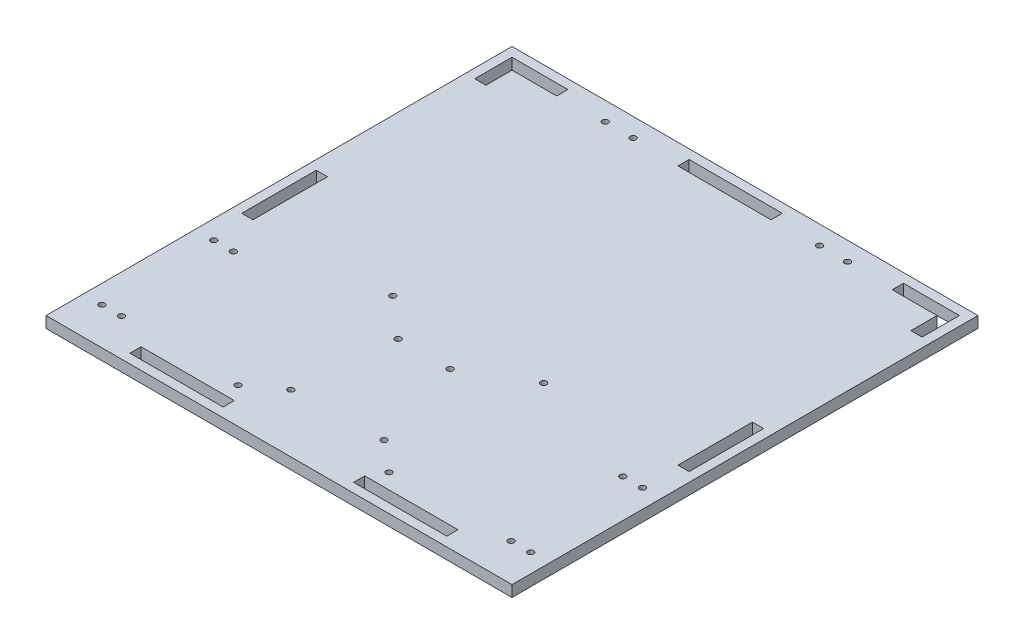
from build123d import *

# Parameters (mm, degrees)
SKETCH1_W           = 250
SKETCH1_H           = 250
BOSS_EXTRUDE1_DEPTH = 6
CUT_EXTRUDE2_REACH  = 8
SKETCH4_R           = 1.6
CUT_EXTRUDE3_REACH  = 8
SKETCH5_R           = 1.6
SKETCH6_W           = 6
SKETCH6_H           = 40
SKETCH6_W_2         = 50
SKETCH6_H_2         = 6
CUT_EXTRUDE6_DEPTH  = 6
CUT_EXTRUDE7_REACH  = 8
SKETCH7_R           = 1.6
CUT_EXTRUDE8_REACH  = 8
SKETCH8_R           = 1.6


with BuildPart() as part:
    # Sketch1 → Boss-Extrude1 (new body)
    with BuildSketch(Plane(origin=(0, 0, 0), x_dir=(1, 0, 0), z_dir=(0, 1, 0))):
        Rectangle(SKETCH1_W, SKETCH1_H)
    extrude(amount=BOSS_EXTRUDE1_DEPTH)

    # Sketch4 → Cut-Extrude2 (cut, up to next)
    with BuildSketch(Plane(origin=(0, 6, 0), x_dir=(1, 0, 0), z_dir=(0, 1, 0)), mode=Mode.PRIVATE) as cut_extrude2_sk1:
        with Locations((-115, -105)):
            Circle(SKETCH4_R)
    cut_extrude2_tool1 = extrude(cut_extrude2_sk1.sketch, amount=-CUT_EXTRUDE2_REACH, mode=Mode.PRIVATE) & part.part
    add(cut_extrude2_tool1.solids().sort_by_distance((-115, 6, 105))[0], mode=Mode.SUBTRACT)
    # Sketch4 → Cut-Extrude2 (cut, up to next)
    with BuildSketch(Plane(origin=(0, 6, 0), x_dir=(1, 0, 0), z_dir=(0, 1, 0)), mode=Mode.PRIVATE) as cut_extrude2_sk2:
        with Locations((-104.5, -105)):
            Circle(SKETCH4_R)
    cut_extrude2_tool2 = extrude(cut_extrude2_sk2.sketch, amount=-CUT_EXTRUDE2_REACH, mode=Mode.PRIVATE) & part.part
    add(cut_extrude2_tool2.solids().sort_by_distance((-104.5, 6, 105))[0], mode=Mode.SUBTRACT)
    # Sketch4 → Cut-Extrude2 (cut, up to next)
    with BuildSketch(Plane(origin=(0, 6, 0), x_dir=(1, 0, 0), z_dir=(0, 1, 0)), mode=Mode.PRIVATE) as cut_extrude2_sk3:
        with Locations((-115, -45)):
            Circle(SKETCH4_R)
    cut_extrude2_tool3 = extrude(cut_extrude2_sk3.sketch, amount=-CUT_EXTRUDE2_REACH, mode=Mode.PRIVATE) & part.part
    add(cut_extrude2_tool3.solids().sort_by_distance((-115, 6, 45))[0], mode=Mode.SUBTRACT)
    # Sketch4 → Cut-Extrude2 (cut, up to next)
    with BuildSketch(Plane(origin=(0, 6, 0), x_dir=(1, 0, 0), z_dir=(0, 1, 0)), mode=Mode.PRIVATE) as cut_extrude2_sk4:
        with Locations((-104.5, -45)):
            Circle(SKETCH4_R)
    cut_extrude2_tool4 = extrude(cut_extrude2_sk4.sketch, amount=-CUT_EXTRUDE2_REACH, mode=Mode.PRIVATE) & part.part
    add(cut_extrude2_tool4.solids().sort_by_distance((-104.5, 6, 45))[0], mode=Mode.SUBTRACT)
    # Sketch4 → Cut-Extrude2 (cut, up to next)
    with BuildSketch(Plane(origin=(0, 6, 0), x_dir=(1, 0, 0), z_dir=(0, 1, 0)), mode=Mode.PRIVATE) as cut_extrude2_sk5:
        with Locations((115, -45)):
            Circle(SKETCH4_R)
    cut_extrude2_tool5 = extrude(cut_extrude2_sk5.sketch, amount=-CUT_EXTRUDE2_REACH, mode=Mode.PRIVATE) & part.part
    add(cut_extrude2_tool5.solids().sort_by_distance((115, 6, 45))[0], mode=Mode.SUBTRACT)
    # Sketch4 → Cut-Extrude2 (cut, up to next)
    with BuildSketch(Plane(origin=(0, 6, 0), x_dir=(1, 0, 0), z_dir=(0, 1, 0)), mode=Mode.PRIVATE) as cut_extrude2_sk6:
        with Locations((104.5, -45)):
            Circle(SKETCH4_R)
    cut_extrude2_tool6 = extrude(cut_extrude2_sk6.sketch, amount=-CUT_EXTRUDE2_REACH, mode=Mode.PRIVATE) & part.part
    add(cut_extrude2_tool6.solids().sort_by_distance((104.5, 6, 45))[0], mode=Mode.SUBTRACT)
    # Sketch4 → Cut-Extrude2 (cut, up to next)
    with BuildSketch(Plane(origin=(0, 6, 0), x_dir=(1, 0, 0), z_dir=(0, 1, 0)), mode=Mode.PRIVATE) as cut_extrude2_sk7:
        with Locations((115, -105)):
            Circle(SKETCH4_R)
    cut_extrude2_tool7 = extrude(cut_extrude2_sk7.sketch, amount=-CUT_EXTRUDE2_REACH, mode=Mode.PRIVATE) & part.part
    add(cut_extrude2_tool7.solids().sort_by_distance((115, 6, 105))[0], mode=Mode.SUBTRACT)
    # Sketch4 → Cut-Extrude2 (cut, up to next)
    with BuildSketch(Plane(origin=(0, 6, 0), x_dir=(1, 0, 0), z_dir=(0, 1, 0)), mode=Mode.PRIVATE) as cut_extrude2_sk8:
        with Locations((104.5, -105)):
            Circle(SKETCH4_R)
    cut_extrude2_tool8 = extrude(cut_extrude2_sk8.sketch, amount=-CUT_EXTRUDE2_REACH, mode=Mode.PRIVATE) & part.part
    add(cut_extrude2_tool8.solids().sort_by_distance((104.5, 6, 105))[0], mode=Mode.SUBTRACT)

    # Sketch5 → Cut-Extrude3 (cut, up to next)
    with BuildSketch(Plane(origin=(0, 6, 0), x_dir=(1, 0, 0), z_dir=(0, 1, 0)), mode=Mode.PRIVATE) as cut_extrude3_sk1:
        with Locations((-65, 115)):
            Circle(SKETCH5_R)
    cut_extrude3_tool1 = extrude(cut_extrude3_sk1.sketch, amount=-CUT_EXTRUDE3_REACH, mode=Mode.PRIVATE) & part.part
    add(cut_extrude3_tool1.solids().sort_by_distance((-65, 6, -115))[0], mode=Mode.SUBTRACT)
    # Sketch5 → Cut-Extrude3 (cut, up to next)
    with BuildSketch(Plane(origin=(0, 6, 0), x_dir=(1, 0, 0), z_dir=(0, 1, 0)), mode=Mode.PRIVATE) as cut_extrude3_sk2:
        with Locations((-50, 115)):
            Circle(SKETCH5_R)
    cut_extrude3_tool2 = extrude(cut_extrude3_sk2.sketch, amount=-CUT_EXTRUDE3_REACH, mode=Mode.PRIVATE) & part.part
    add(cut_extrude3_tool2.solids().sort_by_distance((-50, 6, -115))[0], mode=Mode.SUBTRACT)
    # Sketch5 → Cut-Extrude3 (cut, up to next)
    with BuildSketch(Plane(origin=(0, 6, 0), x_dir=(1, 0, 0), z_dir=(0, 1, 0)), mode=Mode.PRIVATE) as cut_extrude3_sk3:
        with Locations((50, 115)):
            Circle(SKETCH5_R)
    cut_extrude3_tool3 = extrude(cut_extrude3_sk3.sketch, amount=-CUT_EXTRUDE3_REACH, mode=Mode.PRIVATE) & part.part
    add(cut_extrude3_tool3.solids().sort_by_distance((50, 6, -115))[0], mode=Mode.SUBTRACT)
    # Sketch5 → Cut-Extrude3 (cut, up to next)
    with BuildSketch(Plane(origin=(0, 6, 0), x_dir=(1, 0, 0), z_dir=(0, 1, 0)), mode=Mode.PRIVATE) as cut_extrude3_sk4:
        with Locations((65, 115)):
            Circle(SKETCH5_R)
    cut_extrude3_tool4 = extrude(cut_extrude3_sk4.sketch, amount=-CUT_EXTRUDE3_REACH, mode=Mode.PRIVATE) & part.part
    add(cut_extrude3_tool4.solids().sort_by_distance((65, 6, -115))[0], mode=Mode.SUBTRACT)

    # Sketch6 → Cut-Extrude6 (cut)
    with BuildSketch(Plane(origin=(0, 6, 0), x_dir=(1, 0, 0), z_dir=(0, 1, 0))):
        Polygon((-90, 120), (-120, 120), (-120, 100), (-114, 100), (-114, 114), (-90, 114), align=None)
        with Locations((-117, -5)):
            Rectangle(SKETCH6_W, SKETCH6_H)
        with Locations((-60, -117)):
            Rectangle(SKETCH6_W_2, SKETCH6_H_2)
        with Locations((60, -117)):
            Rectangle(SKETCH6_W_2, SKETCH6_H_2)
        Polygon((120, 100), (120, 120), (90, 120), (90, 114), (114, 114), (114, 100), align=None)
        with Locations((117, -5)):
            Rectangle(SKETCH6_W, SKETCH6_H)
        with Locations((0, 117)):
            Rectangle(SKETCH6_W_2, SKETCH6_H_2)
    extrude(amount=-CUT_EXTRUDE6_DEPTH, mode=Mode.SUBTRACT)

    # Sketch7 → Cut-Extrude7 (cut, up to next)
    with BuildSketch(Plane(origin=(0, 0, 0), x_dir=(-1, 0, 0), z_dir=(0, -1, 0)), mode=Mode.PRIVATE) as cut_extrude7_sk1:
        with Locations((19.693028717, -41.4)):
            Circle(SKETCH7_R)
    cut_extrude7_tool1 = extrude(cut_extrude7_sk1.sketch, amount=-CUT_EXTRUDE7_REACH, mode=Mode.PRIVATE) & part.part
    add(cut_extrude7_tool1.solids().sort_by_distance((-19.693029, 0, 41.4))[0], mode=Mode.SUBTRACT)
    # Sketch7 → Cut-Extrude7 (cut, up to next)
    with BuildSketch(Plane(origin=(0, 0, 0), x_dir=(-1, 0, 0), z_dir=(0, -1, 0)), mode=Mode.PRIVATE) as cut_extrude7_sk2:
        with Locations((-8.206971283, -41.4)):
            Circle(SKETCH7_R)
    cut_extrude7_tool2 = extrude(cut_extrude7_sk2.sketch, amount=-CUT_EXTRUDE7_REACH, mode=Mode.PRIVATE) & part.part
    add(cut_extrude7_tool2.solids().sort_by_distance((8.206971, 0, 41.4))[0], mode=Mode.SUBTRACT)
    # Sketch7 → Cut-Extrude7 (cut, up to next)
    with BuildSketch(Plane(origin=(0, 0, 0), x_dir=(-1, 0, 0), z_dir=(0, -1, 0)), mode=Mode.PRIVATE) as cut_extrude7_sk3:
        with Locations((-23.506971283, -92.2)):
            Circle(SKETCH7_R)
    cut_extrude7_tool3 = extrude(cut_extrude7_sk3.sketch, amount=-CUT_EXTRUDE7_REACH, mode=Mode.PRIVATE) & part.part
    add(cut_extrude7_tool3.solids().sort_by_distance((23.506971, 0, 92.2))[0], mode=Mode.SUBTRACT)
    # Sketch7 → Cut-Extrude7 (cut, up to next)
    with BuildSketch(Plane(origin=(0, 0, 0), x_dir=(-1, 0, 0), z_dir=(0, -1, 0)), mode=Mode.PRIVATE) as cut_extrude7_sk4:
        with Locations((24.793028717, -93.8)):
            Circle(SKETCH7_R)
    cut_extrude7_tool4 = extrude(cut_extrude7_sk4.sketch, amount=-CUT_EXTRUDE7_REACH, mode=Mode.PRIVATE) & part.part
    add(cut_extrude7_tool4.solids().sort_by_distance((-24.793029, 0, 93.8))[0], mode=Mode.SUBTRACT)

    # Sketch8 → Cut-Extrude8 (cut, up to next)
    with BuildSketch(Plane(origin=(0, 0, 0), x_dir=(-1, 0, 0), z_dir=(0, -1, 0)), mode=Mode.PRIVATE) as cut_extrude8_sk1:
        with Locations((41.143028717, -105.838250208)):
            Circle(SKETCH8_R)
    cut_extrude8_tool1 = extrude(cut_extrude8_sk1.sketch, amount=-CUT_EXTRUDE8_REACH, mode=Mode.PRIVATE) & part.part
    add(cut_extrude8_tool1.solids().sort_by_distance((-41.143029, 0, 105.83825))[0], mode=Mode.SUBTRACT)
    # Sketch8 → Cut-Extrude8 (cut, up to next)
    with BuildSketch(Plane(origin=(0, 0, 0), x_dir=(-1, 0, 0), z_dir=(0, -1, 0)), mode=Mode.PRIVATE) as cut_extrude8_sk2:
        with Locations((41.143028717, -22.838250208)):
            Circle(SKETCH8_R)
    cut_extrude8_tool2 = extrude(cut_extrude8_sk2.sketch, amount=-CUT_EXTRUDE8_REACH, mode=Mode.PRIVATE) & part.part
    add(cut_extrude8_tool2.solids().sort_by_distance((-41.143029, 0, 22.83825))[0], mode=Mode.SUBTRACT)
    # Sketch8 → Cut-Extrude8 (cut, up to next)
    with BuildSketch(Plane(origin=(0, 0, 0), x_dir=(-1, 0, 0), z_dir=(0, -1, 0)), mode=Mode.PRIVATE) as cut_extrude8_sk3:
        with Locations((-39.856971283, -22.838250208)):
            Circle(SKETCH8_R)
    cut_extrude8_tool3 = extrude(cut_extrude8_sk3.sketch, amount=-CUT_EXTRUDE8_REACH, mode=Mode.PRIVATE) & part.part
    add(cut_extrude8_tool3.solids().sort_by_distance((39.856971, 0, 22.83825))[0], mode=Mode.SUBTRACT)
    # Sketch8 → Cut-Extrude8 (cut, up to next)
    with BuildSketch(Plane(origin=(0, 0, 0), x_dir=(-1, 0, 0), z_dir=(0, -1, 0)), mode=Mode.PRIVATE) as cut_extrude8_sk4:
        with Locations((-39.856971283, -105.838250208)):
            Circle(SKETCH8_R)
    cut_extrude8_tool4 = extrude(cut_extrude8_sk4.sketch, amount=-CUT_EXTRUDE8_REACH, mode=Mode.PRIVATE) & part.part
    add(cut_extrude8_tool4.solids().sort_by_distance((39.856971, 0, 105.83825))[0], mode=Mode.SUBTRACT)


solid = part.part
